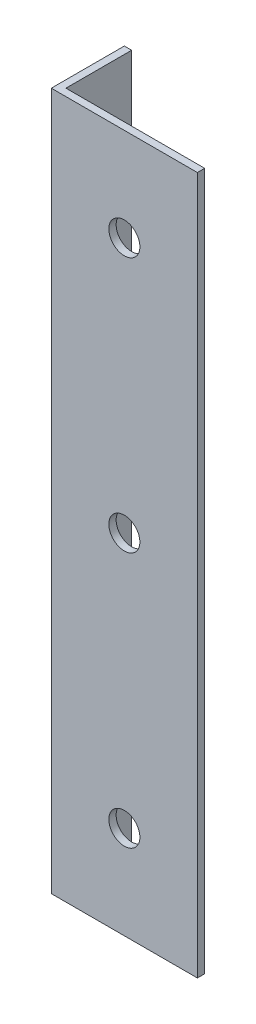
from build123d import *

# Parameters (mm, degrees)
EXTRUDE_1_DEPTH     = 191
SKETCH_2_R          = 4.25
CUT_EXTRUDE_1_DEPTH = 21
SKETCH_3_R          = 2.25
CUT_EXTRUDE_2_DEPTH = 41


with BuildPart() as part:
    # Эскиз1 → Бобышка-Вытянуть1 (new body)
    with BuildSketch(Plane(origin=(0, 0, 0), x_dir=(1, 0, 0), z_dir=(0, 1, 0))):
        Polygon((0, 0), (0, 20), (2, 20), (2, 2), (40, 2), (40, 0), align=None)
    extrude(amount=EXTRUDE_1_DEPTH)

    # Эскиз2 → Вырез-Вытянуть1 (cut, through all)
    with BuildSketch(Plane.XY):
        with Locations((20, 165.5)):
            Circle(SKETCH_2_R)
        with Locations((20, 95.5)):
            Circle(SKETCH_2_R)
        with Locations((20, 25.5)):
            Circle(SKETCH_2_R)
    extrude(amount=-CUT_EXTRUDE_1_DEPTH, mode=Mode.SUBTRACT)

    # Эскиз3 → Вырез-Вытянуть2 (cut, through all)
    with BuildSketch(Plane.ZY):
        with Locations((-10, 12)):
            Circle(SKETCH_3_R)
        with Locations((-10, 179)):
            Circle(SKETCH_3_R)
    extrude(amount=-CUT_EXTRUDE_2_DEPTH, mode=Mode.SUBTRACT)


solid = part.part
